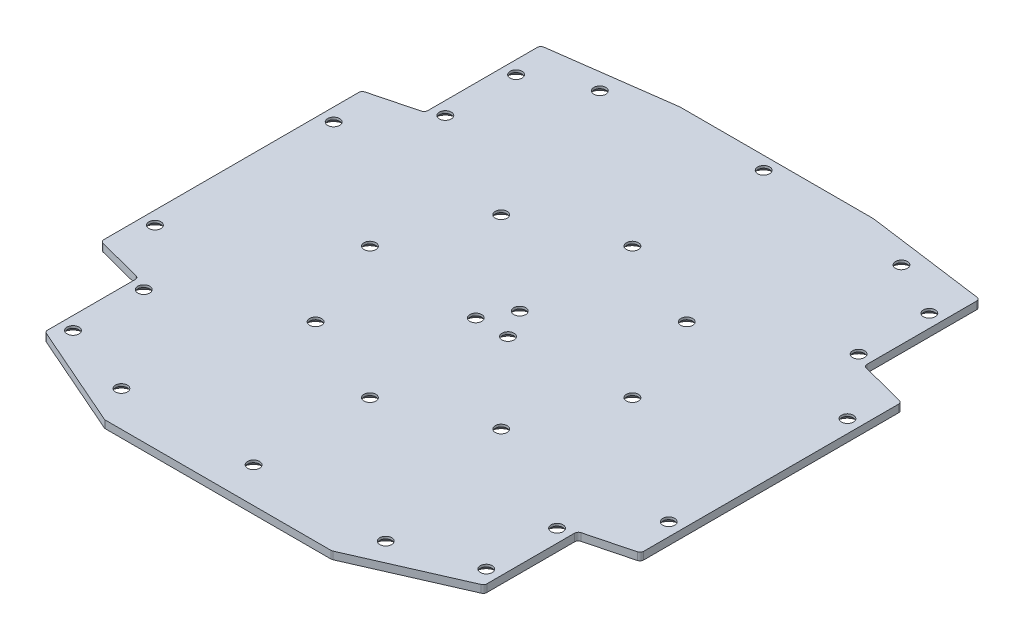
from build123d import *

# Parameters (mm, degrees)
SKETCH1_W                     = 161
SKETCH1_H                     = 150
SKETCH1_W_2                   = 15.5
SKETCH1_H_2                   = 23
BOSS_EXTRUDE1_DEPTH           = 2.032
CSK_FOR_M3_SFHCS1_AT_2_COUNT  = 2
CSK_FOR_M3_SFHCS1_AT_2_PITCH  = 26.979181982
CSK_FOR_M3_SFHCS1_AT_3_COUNT  = 2
CSK_FOR_M3_SFHCS1_AT_3_PITCH  = 49.851028074
CSK_FOR_M3_SFHCS1_AT_4_COUNT  = 2
CSK_FOR_M3_SFHCS1_AT_4_PITCH  = 65.133507042
CSK_FOR_M3_SFHCS1_AT_5_COUNT  = 2
CSK_FOR_M3_SFHCS1_AT_5_PITCH  = 70.5
CSK_FOR_M3_SFHCS1_AT_6_COUNT  = 2
CSK_FOR_M3_SFHCS1_AT_6_PITCH  = 65.133507042
CSK_FOR_M3_SFHCS1_AT_7_COUNT  = 2
CSK_FOR_M3_SFHCS1_AT_7_PITCH  = 49.851028074
CSK_FOR_M3_SFHCS1_AT_8_COUNT  = 2
CSK_FOR_M3_SFHCS1_AT_8_PITCH  = 26.979181982
CSK_FOR_M3_SFHCS1_AT_9_COUNT  = 2
CSK_FOR_M3_SFHCS1_AT_9_PITCH  = 40.25
CSK_FOR_M3_SFHCS1_AT_10_COUNT = 2
CSK_FOR_M3_SFHCS1_AT_10_PITCH = 33.035019298
CSK_FOR_M3_SFHCS1_AT_11_COUNT = 2
CSK_FOR_M3_SFHCS1_AT_11_PITCH = 33.035019298
CUT_EXTRUDE1_DEPTH            = 3.032
FILLET1_R                     = 1
CSK_FOR_M3_SFHCS2_AT_2_COUNT  = 2
CSK_FOR_M3_SFHCS2_AT_2_PITCH  = 35.5
CSK_FOR_M3_SFHCS2_AT_3_COUNT  = 2
CSK_FOR_M3_SFHCS2_AT_3_PITCH  = 81.038571063
CSK_FOR_M3_SFHCS2_AT_4_COUNT  = 2
CSK_FOR_M3_SFHCS2_AT_4_PITCH  = 61.288253361
CSK_FOR_M3_SFHCS2_AT_5_COUNT  = 2
CSK_FOR_M3_SFHCS2_AT_5_PITCH  = 55.939699677
CSK_FOR_M3_SFHCS2_AT_6_COUNT  = 2
CSK_FOR_M3_SFHCS2_AT_6_PITCH  = 55.939699677
CSK_FOR_M3_SFHCS2_AT_7_COUNT  = 2
CSK_FOR_M3_SFHCS2_AT_7_PITCH  = 61.288253361
CSK_FOR_M3_SFHCS2_AT_8_COUNT  = 2
CSK_FOR_M3_SFHCS2_AT_8_PITCH  = 81.038571063
CSK_FOR_M3_SFHCS2_AT_9_COUNT  = 2
CSK_FOR_M3_SFHCS2_AT_9_PITCH  = 35.5
CSK_FOR_M3_SFHCS2_AT_10_COUNT = 2
CSK_FOR_M3_SFHCS2_AT_10_PITCH = 113.80355882
CSK_FOR_M3_SFHCS2_AT_11_COUNT = 2
CSK_FOR_M3_SFHCS2_AT_11_PITCH = 120.537338613
CSK_FOR_M3_SFHCS2_AT_12_COUNT = 2
CSK_FOR_M3_SFHCS2_AT_12_PITCH = 137.68169813
CSK_FOR_M3_SFHCS2_AT_13_COUNT = 2
CSK_FOR_M3_SFHCS2_AT_13_PITCH = 137.68169813
CSK_FOR_M3_SFHCS2_AT_14_COUNT = 2
CSK_FOR_M3_SFHCS2_AT_14_PITCH = 120.537338613
CSK_FOR_M3_SFHCS2_AT_15_COUNT = 2
CSK_FOR_M3_SFHCS2_AT_15_PITCH = 113.80355882
CSK_FOR_M3_SFHCS2_AT_16_COUNT = 2
CSK_FOR_M3_SFHCS2_AT_16_PITCH = 139.508064283
CSK_FOR_M3_SFHCS2_AT_17_COUNT = 2
CSK_FOR_M3_SFHCS2_AT_17_PITCH = 137
CSK_FOR_M3_SFHCS2_AT_18_COUNT = 2
CSK_FOR_M3_SFHCS2_AT_18_PITCH = 139.508064283


with BuildPart() as part:
    # Sketch1 → Boss-Extrude1 (new body)
    with BuildSketch(Plane(origin=(0, 0, 0), x_dir=(1, 0, 0), z_dir=(0, 1, 0))):
        with Locations((0, -1)):
            Rectangle(SKETCH1_W, SKETCH1_H)
        with Locations((-66.75, 50)):
            Rectangle(SKETCH1_W_2, SKETCH1_H_2, mode=Mode.SUBTRACT)
        with Locations((66.75, 50)):
            Rectangle(SKETCH1_W_2, SKETCH1_H_2, mode=Mode.SUBTRACT)
        with Locations((66.75, -50)):
            Rectangle(SKETCH1_W_2, SKETCH1_H_2, mode=Mode.SUBTRACT)
        with Locations((-66.75, -50)):
            Rectangle(SKETCH1_W_2, SKETCH1_H_2, mode=Mode.SUBTRACT)
    extrude(amount=BOSS_EXTRUDE1_DEPTH)

    # Sketch2 → CSK for M3 SFHCS1 (revolve, cut)
    with BuildSketch(Plane(origin=(0, 0, 35.25), x_dir=(0, 0, -1), z_dir=(1, 0, 0))):
        Polygon((0, 0), (0, 2.032), (1.6, 2.032), (1.6, 1.4), (3, 0), align=None)
    csk_for_m3_sfhcs1 = revolve(axis=Axis((0, -6.35, 35.25), (0, 1, 0)), mode=Mode.SUBTRACT)

    # CSK for M3 SFHCS1 at 2: CSK for M3 SFHCS1 ×2
    with Locations(*[Vector(0.923879533, 0, -0.382683432) * (i * CSK_FOR_M3_SFHCS1_AT_2_PITCH) for i in range(1, CSK_FOR_M3_SFHCS1_AT_2_COUNT)]):
        add(csk_for_m3_sfhcs1, mode=Mode.SUBTRACT)

    # CSK for M3 SFHCS1 at 3: CSK for M3 SFHCS1 ×2
    with Locations(*[Vector(0.707106781, 0, -0.707106781) * (i * CSK_FOR_M3_SFHCS1_AT_3_PITCH) for i in range(1, CSK_FOR_M3_SFHCS1_AT_3_COUNT)]):
        add(csk_for_m3_sfhcs1, mode=Mode.SUBTRACT)

    # CSK for M3 SFHCS1 at 4: CSK for M3 SFHCS1 ×2
    with Locations(*[Vector(0.382683432, 0, -0.923879533) * (i * CSK_FOR_M3_SFHCS1_AT_4_PITCH) for i in range(1, CSK_FOR_M3_SFHCS1_AT_4_COUNT)]):
        add(csk_for_m3_sfhcs1, mode=Mode.SUBTRACT)

    # CSK for M3 SFHCS1 at 5: CSK for M3 SFHCS1 ×2
    with Locations(*[(0, 0, -i * CSK_FOR_M3_SFHCS1_AT_5_PITCH) for i in range(1, CSK_FOR_M3_SFHCS1_AT_5_COUNT)]):
        add(csk_for_m3_sfhcs1, mode=Mode.SUBTRACT)

    # CSK for M3 SFHCS1 at 6: CSK for M3 SFHCS1 ×2
    with Locations(*[Vector(-0.382683432, 0, -0.923879533) * (i * CSK_FOR_M3_SFHCS1_AT_6_PITCH) for i in range(1, CSK_FOR_M3_SFHCS1_AT_6_COUNT)]):
        add(csk_for_m3_sfhcs1, mode=Mode.SUBTRACT)

    # CSK for M3 SFHCS1 at 7: CSK for M3 SFHCS1 ×2
    with Locations(*[Vector(-0.707106781, 0, -0.707106781) * (i * CSK_FOR_M3_SFHCS1_AT_7_PITCH) for i in range(1, CSK_FOR_M3_SFHCS1_AT_7_COUNT)]):
        add(csk_for_m3_sfhcs1, mode=Mode.SUBTRACT)

    # CSK for M3 SFHCS1 at 8: CSK for M3 SFHCS1 ×2
    with Locations(*[Vector(-0.923879533, 0, -0.382683432) * (i * CSK_FOR_M3_SFHCS1_AT_8_PITCH) for i in range(1, CSK_FOR_M3_SFHCS1_AT_8_COUNT)]):
        add(csk_for_m3_sfhcs1, mode=Mode.SUBTRACT)

    # CSK for M3 SFHCS1 at 9: CSK for M3 SFHCS1 ×2
    with Locations(*[(0, 0, -i * CSK_FOR_M3_SFHCS1_AT_9_PITCH) for i in range(1, CSK_FOR_M3_SFHCS1_AT_9_COUNT)]):
        add(csk_for_m3_sfhcs1, mode=Mode.SUBTRACT)

    # CSK for M3 SFHCS1 at 10: CSK for M3 SFHCS1 ×2
    with Locations(*[Vector(-0.131076873, 0, -0.991372207) * (i * CSK_FOR_M3_SFHCS1_AT_10_PITCH) for i in range(1, CSK_FOR_M3_SFHCS1_AT_10_COUNT)]):
        add(csk_for_m3_sfhcs1, mode=Mode.SUBTRACT)

    # CSK for M3 SFHCS1 at 11: CSK for M3 SFHCS1 ×2
    with Locations(*[Vector(0.131076873, 0, -0.991372207) * (i * CSK_FOR_M3_SFHCS1_AT_11_PITCH) for i in range(1, CSK_FOR_M3_SFHCS1_AT_11_COUNT)]):
        add(csk_for_m3_sfhcs1, mode=Mode.SUBTRACT)

    # Sketch4 → Cut-Extrude1 (cut, through all)
    with BuildSketch(Plane.XZ):
        Polygon((59, -38.5), (72.5, -35), (72.5, 35), (59, 38.5), (59, 63.5), (30.5, 76), (80.5, 76), (80.5, -74), (26, -74), (59, -69.528648916), align=None)
        Polygon((-80.5, 76), (-80.5, -74), (-26, -74), (-59, -69.528648916), (-59, -38.5), (-72.5, -35), (-72.5, 35), (-59, 38.5), (-59, 63.5), (-30.5, 76), align=None)
    extrude(amount=-CUT_EXTRUDE1_DEPTH, mode=Mode.SUBTRACT)

    # Fillet1
    fillet1_edges = [part.edges().sort_by_distance(p)[0] for p in [
        (-59, 1.016, -38.5),
        (59, 1.016, -69.528648916),
        (72.5, 1.016, -35),
        (72.5, 1.016, 35),
        (59, 1.016, 63.5),
        (30.5, 1.016, 76),
        (26, 1.016, -74),
        (-30.5, 1.016, 76),
        (-59, 1.016, 63.5),
        (-72.5, 1.016, 35),
        (-72.5, 1.016, -35),
        (-59, 1.016, -69.528648916),
        (-26, 1.016, -74),
        (59, 1.016, -38.5),
        (59, 1.016, 38.5),
        (-59, 1.016, 38.5),
    ]]
    fillet(fillet1_edges, radius=FILLET1_R)

    # Sketch5 → CSK for M3 SFHCS2 (revolve, cut)
    with BuildSketch(Plane(origin=(0, 0, 66.5), x_dir=(0, 0, -1), z_dir=(1, 0, 0))):
        Polygon((0, 0), (0, 2.032), (1.6, 2.032), (1.6, 1.4), (3, 0), align=None)
    csk_for_m3_sfhcs2 = revolve(axis=Axis((0, -6.35, 66.5), (0, 1, 0)), mode=Mode.SUBTRACT)

    # CSK for M3 SFHCS2 at 2: CSK for M3 SFHCS2 ×2
    with Locations(*[(-i * CSK_FOR_M3_SFHCS2_AT_2_PITCH, 0, 0) for i in range(1, CSK_FOR_M3_SFHCS2_AT_2_COUNT)]):
        add(csk_for_m3_sfhcs2, mode=Mode.SUBTRACT)

    # CSK for M3 SFHCS2 at 3: CSK for M3 SFHCS2 ×2
    with Locations(*[Vector(-0.851446405, 0, -0.524441626) * (i * CSK_FOR_M3_SFHCS2_AT_3_PITCH) for i in range(1, CSK_FOR_M3_SFHCS2_AT_3_COUNT)]):
        add(csk_for_m3_sfhcs2, mode=Mode.SUBTRACT)

    # CSK for M3 SFHCS2 at 4: CSK for M3 SFHCS2 ×2
    with Locations(*[Vector(-0.905556888, 0, -0.424224849) * (i * CSK_FOR_M3_SFHCS2_AT_4_PITCH) for i in range(1, CSK_FOR_M3_SFHCS2_AT_4_COUNT)]):
        add(csk_for_m3_sfhcs2, mode=Mode.SUBTRACT)

    # CSK for M3 SFHCS2 at 5: CSK for M3 SFHCS2 ×2
    with Locations(*[Vector(-0.992139756, 0, -0.125134744) * (i * CSK_FOR_M3_SFHCS2_AT_5_PITCH) for i in range(1, CSK_FOR_M3_SFHCS2_AT_5_COUNT)]):
        add(csk_for_m3_sfhcs2, mode=Mode.SUBTRACT)

    # CSK for M3 SFHCS2 at 6: CSK for M3 SFHCS2 ×2
    with Locations(*[Vector(0.992139756, 0, -0.125134744) * (i * CSK_FOR_M3_SFHCS2_AT_6_PITCH) for i in range(1, CSK_FOR_M3_SFHCS2_AT_6_COUNT)]):
        add(csk_for_m3_sfhcs2, mode=Mode.SUBTRACT)

    # CSK for M3 SFHCS2 at 7: CSK for M3 SFHCS2 ×2
    with Locations(*[Vector(0.905556888, 0, -0.424224849) * (i * CSK_FOR_M3_SFHCS2_AT_7_PITCH) for i in range(1, CSK_FOR_M3_SFHCS2_AT_7_COUNT)]):
        add(csk_for_m3_sfhcs2, mode=Mode.SUBTRACT)

    # CSK for M3 SFHCS2 at 8: CSK for M3 SFHCS2 ×2
    with Locations(*[Vector(0.851446405, 0, -0.524441626) * (i * CSK_FOR_M3_SFHCS2_AT_8_PITCH) for i in range(1, CSK_FOR_M3_SFHCS2_AT_8_COUNT)]):
        add(csk_for_m3_sfhcs2, mode=Mode.SUBTRACT)

    # CSK for M3 SFHCS2 at 9: CSK for M3 SFHCS2 ×2
    with Locations(*[(i * CSK_FOR_M3_SFHCS2_AT_9_PITCH, 0, 0) for i in range(1, CSK_FOR_M3_SFHCS2_AT_9_COUNT)]):
        add(csk_for_m3_sfhcs2, mode=Mode.SUBTRACT)

    # CSK for M3 SFHCS2 at 10: CSK for M3 SFHCS2 ×2
    with Locations(*[Vector(0.606307928, 0, -0.795229964) * (i * CSK_FOR_M3_SFHCS2_AT_10_PITCH) for i in range(1, CSK_FOR_M3_SFHCS2_AT_10_COUNT)]):
        add(csk_for_m3_sfhcs2, mode=Mode.SUBTRACT)

    # CSK for M3 SFHCS2 at 11: CSK for M3 SFHCS2 ×2
    with Locations(*[Vector(0.46043824, 0, -0.887691741) * (i * CSK_FOR_M3_SFHCS2_AT_11_PITCH) for i in range(1, CSK_FOR_M3_SFHCS2_AT_11_COUNT)]):
        add(csk_for_m3_sfhcs2, mode=Mode.SUBTRACT)

    # CSK for M3 SFHCS2 at 12: CSK for M3 SFHCS2 ×2
    with Locations(*[Vector(0.403103686, 0, -0.915154314) * (i * CSK_FOR_M3_SFHCS2_AT_12_PITCH) for i in range(1, CSK_FOR_M3_SFHCS2_AT_12_COUNT)]):
        add(csk_for_m3_sfhcs2, mode=Mode.SUBTRACT)

    # CSK for M3 SFHCS2 at 13: CSK for M3 SFHCS2 ×2
    with Locations(*[Vector(-0.403103686, 0, -0.915154314) * (i * CSK_FOR_M3_SFHCS2_AT_13_PITCH) for i in range(1, CSK_FOR_M3_SFHCS2_AT_13_COUNT)]):
        add(csk_for_m3_sfhcs2, mode=Mode.SUBTRACT)

    # CSK for M3 SFHCS2 at 14: CSK for M3 SFHCS2 ×2
    with Locations(*[Vector(-0.46043824, 0, -0.887691741) * (i * CSK_FOR_M3_SFHCS2_AT_14_PITCH) for i in range(1, CSK_FOR_M3_SFHCS2_AT_14_COUNT)]):
        add(csk_for_m3_sfhcs2, mode=Mode.SUBTRACT)

    # CSK for M3 SFHCS2 at 15: CSK for M3 SFHCS2 ×2
    with Locations(*[Vector(-0.606307928, 0, -0.795229964) * (i * CSK_FOR_M3_SFHCS2_AT_15_PITCH) for i in range(1, CSK_FOR_M3_SFHCS2_AT_15_COUNT)]):
        add(csk_for_m3_sfhcs2, mode=Mode.SUBTRACT)

    # CSK for M3 SFHCS2 at 16: CSK for M3 SFHCS2 ×2
    with Locations(*[Vector(0.290305799, 0, -0.956933928) * (i * CSK_FOR_M3_SFHCS2_AT_16_PITCH) for i in range(1, CSK_FOR_M3_SFHCS2_AT_16_COUNT)]):
        add(csk_for_m3_sfhcs2, mode=Mode.SUBTRACT)

    # CSK for M3 SFHCS2 at 17: CSK for M3 SFHCS2 ×2
    with Locations(*[(0, 0, -i * CSK_FOR_M3_SFHCS2_AT_17_PITCH) for i in range(1, CSK_FOR_M3_SFHCS2_AT_17_COUNT)]):
        add(csk_for_m3_sfhcs2, mode=Mode.SUBTRACT)

    # CSK for M3 SFHCS2 at 18: CSK for M3 SFHCS2 ×2
    with Locations(*[Vector(-0.290305799, 0, -0.956933928) * (i * CSK_FOR_M3_SFHCS2_AT_18_PITCH) for i in range(1, CSK_FOR_M3_SFHCS2_AT_18_COUNT)]):
        add(csk_for_m3_sfhcs2, mode=Mode.SUBTRACT)


solid = part.part
